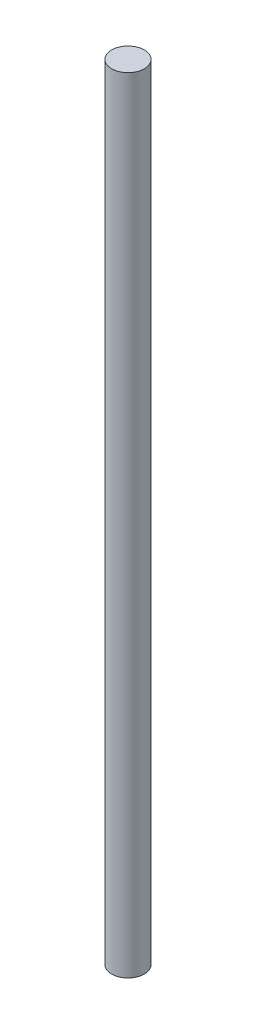
from build123d import *

# Parameters (mm, degrees)
SKETCH1_R           = 4.7625
BOSS_EXTRUDE1_DEPTH = 228.6


with BuildPart() as part:
    # Sketch1 → Boss-Extrude1 (new body)
    with BuildSketch(Plane(origin=(0, 0, 0), x_dir=(1, 0, 0), z_dir=(0, 1, 0))):
        Circle(SKETCH1_R)
    extrude(amount=BOSS_EXTRUDE1_DEPTH)


solid = part.part
